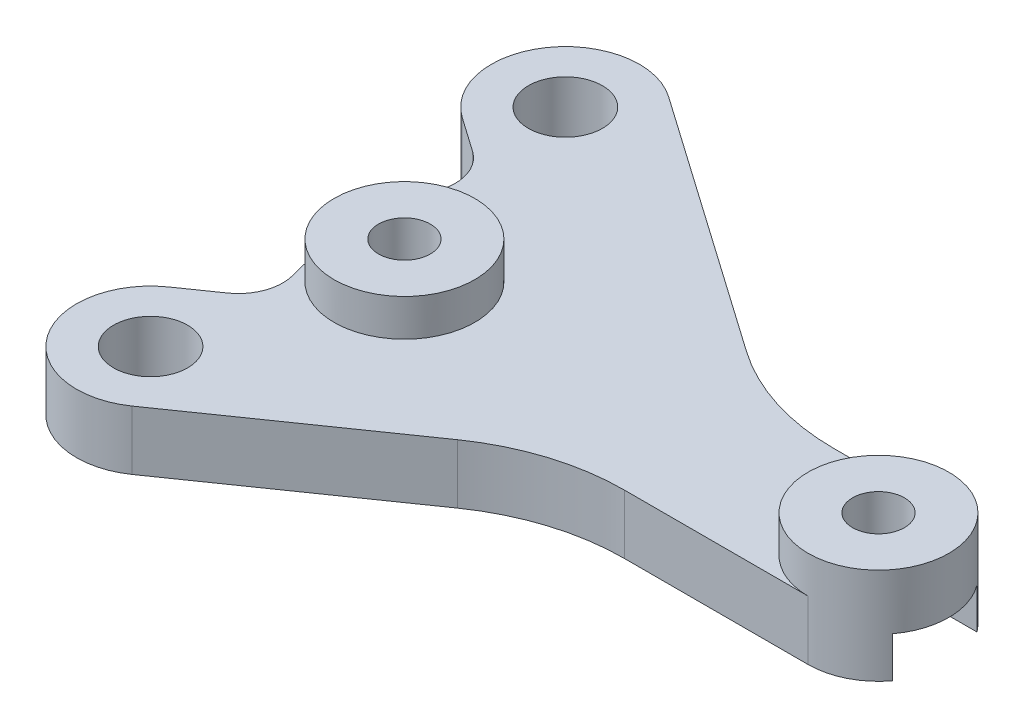
from build123d import *

# Parameters (mm, degrees)
SKETCH1_R           = 2.5
SKETCH1_R_2         = 1.75
BOSS_EXTRUDE1_DEPTH = 4
SKETCH3_R           = 4.75
SKETCH3_R_2         = 1.75
BOSS_EXTRUDE2_DEPTH = 2.5
FILLET1_R           = 3
FILLET2_R           = 15
SKETCH4_R           = 1.75
CUT_EXTRUDE1_DEPTH  = 2.75


with BuildPart() as part:
    # Sketch1 → Boss-Extrude1 (new body)
    with BuildSketch(Plane(origin=(0, 0, 0), x_dir=(1, 0, 0), z_dir=(0, 1, 0))):
        with BuildLine():
            Line((-33.743770102, 11.787151842), (-29.558909379, 8.857749335))
            ThreePointArc((-29.558909379, 8.857749335), (-30.943257909, 1.876678146), (-29.553838003, -5.103385472))
            Line((-29.553838003, -5.103385472), (-33.733356926, -8.013259417))
            ThreePointArc((-33.733356926, -8.013259417), (-34.979887519, -14.973587102), (-28.019559835, -16.220117695))
            Line((-28.019559835, -16.220117695), (-11.208684115, -4.516012477))
            Line((-11.208684115, -4.516012477), (5.907787468, -4.516012477))
            ThreePointArc((5.907787468, -4.516012477), (10.657787468, 0.233987523), (5.907787468, 4.983987523))
            Line((5.907787468, 4.983987523), (-6.587027339, 4.983987523))
            Line((-6.587027339, 4.983987523), (-28.009146659, 19.979471047))
            ThreePointArc((-28.009146659, 19.979471047), (-34.972617983, 18.750623166), (-33.743770102, 11.787151842))
        make_face()
        with Locations((-30.87645838, 15.883311444)):
            Circle(SKETCH1_R, mode=Mode.SUBTRACT)
        with Locations((-30.87645838, -12.116688556)):
            Circle(SKETCH1_R, mode=Mode.SUBTRACT)
        with Locations((-26.092212532, 0.233987523)):
            Circle(SKETCH1_R_2, mode=Mode.SUBTRACT)
        with Locations((5.907787468, 0.233987523)):
            Circle(SKETCH1_R_2, mode=Mode.SUBTRACT)
    extrude(amount=BOSS_EXTRUDE1_DEPTH)

    # Sketch3 → Boss-Extrude2 (add)
    with BuildSketch(Plane(origin=(0, 4, 0), x_dir=(1, 0, 0), z_dir=(0, 1, 0))):
        with Locations((-26.092212532, 0.233987523)):
            Circle(SKETCH3_R)
        with Locations((-26.092212532, 0.233987523)):
            Circle(SKETCH3_R_2, mode=Mode.SUBTRACT)
        with Locations((5.907787468, 0.233987523)):
            Circle(SKETCH3_R)
        with Locations((5.907787468, 0.233987523)):
            Circle(SKETCH3_R_2, mode=Mode.SUBTRACT)
    extrude(amount=BOSS_EXTRUDE2_DEPTH)

    # Fillet1
    fillet1_edges = [part.edges().sort_by_distance(p)[0] for p in [
        (-29.553838003, 2, 5.103385472),
        (-29.558909379, 2, -8.857749335),
    ]]
    fillet(fillet1_edges, radius=FILLET1_R)

    # Fillet2
    fillet2_edges = [part.edges().sort_by_distance(p)[0] for p in [
        (-11.208684115, 2, 4.516012477),
        (-6.587027339, 2, -4.983987523),
    ]]
    fillet(fillet2_edges, radius=FILLET2_R)

    # Sketch4 → Cut-Extrude1 (cut)
    with BuildSketch(Plane.XZ):
        with BuildLine():
            ThreePointArc((-2.629044497, 2.616012477), (-3.092212532, -0.233987523), (-2.629044497, -3.083987523))
            Line((-2.629044497, -3.083987523), (9.707787468, -3.083987523))
            ThreePointArc((9.707787468, -3.083987523), (10.657787468, -0.233987523), (9.707787468, 2.616012477))
            Line((9.707787468, 2.616012477), (-2.629044497, 2.616012477))
        make_face()
        with Locations((5.907787468, -0.233987523)):
            Circle(SKETCH4_R, mode=Mode.SUBTRACT)
        with BuildLine():
            Line((-30.90374362, -3.083987523), (-17.555380567, -3.083987523))
            ThreePointArc((-17.555380567, -3.083987523), (-17.092212532, -0.233987523), (-17.555380567, 2.616012477))
            Line((-17.555380567, 2.616012477), (-30.380287253, 2.616012477))
            ThreePointArc((-30.380287253, 2.616012477), (-30.866740114, -0.213350056), (-30.90374362, -3.083987523))
        make_face()
        with Locations((-26.092212532, -0.233987523)):
            Circle(SKETCH4_R, mode=Mode.SUBTRACT)
    extrude(amount=-CUT_EXTRUDE1_DEPTH, mode=Mode.SUBTRACT)


solid = part.part
